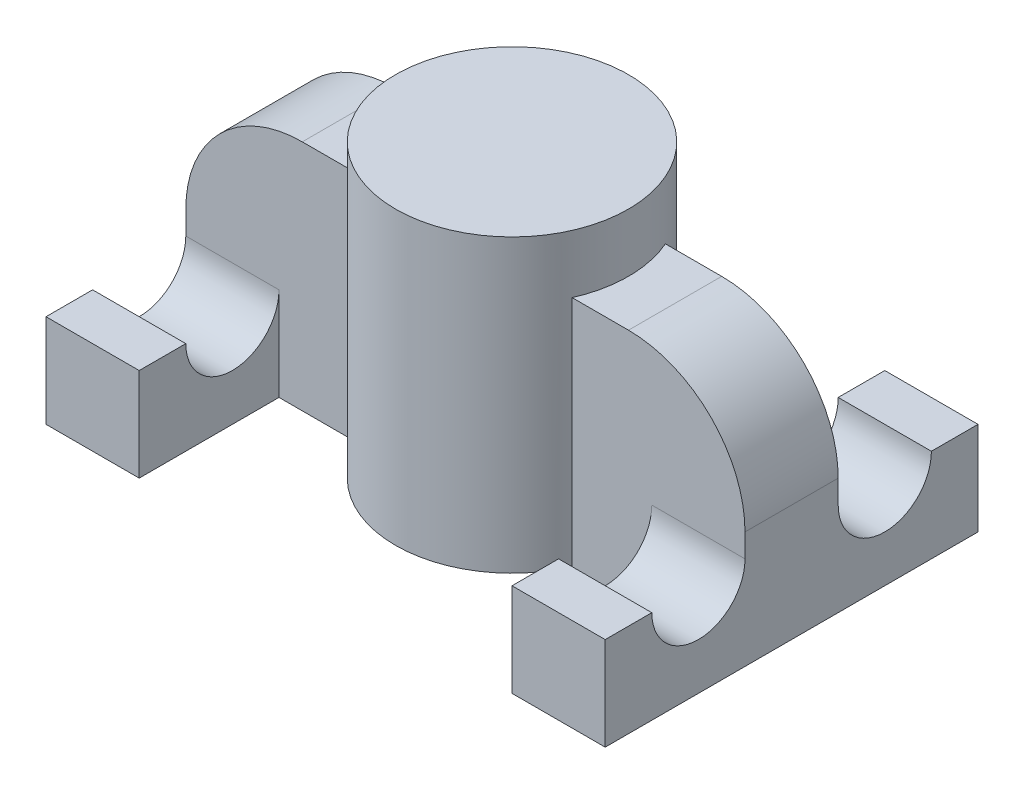
from build123d import *

# Parameters (mm, degrees)
SKETCH1_R                = 10
PEN_CAP_DEPTH            = 25
SKETCH2_W                = 48
SKETCH2_H                = 8
HOOK_STRUCTURE_DEPTH     = 20
PEN_CENTERING_HOLE_D     = 12.5
PEN_CENTERING_HOLE_DEPTH = 15
PEN_CENTERING_HOLE_TIP   = 6.25
HOOKS_DEPTH              = 8
CORNER_DEC_R             = 10


with BuildPart() as part:
    # Sketch1 → Pen Cap (new body)
    with BuildSketch(Plane(origin=(0, 0, 0), x_dir=(1, 0, 0), z_dir=(0, 1, 0))):
        Circle(SKETCH1_R)
    extrude(amount=PEN_CAP_DEPTH)

    # Sketch2 → Hook Structure (add)
    with BuildSketch(Plane.XZ):
        Rectangle(SKETCH2_W, SKETCH2_H)
    extrude(amount=-HOOK_STRUCTURE_DEPTH)

    # Pen Centering Hole
    with Locations(Plane.XZ):
        with Locations((0, 0)):
            Hole(PEN_CENTERING_HOLE_D / 2, depth=PEN_CENTERING_HOLE_DEPTH)
            with Locations((0, 0, -(PEN_CENTERING_HOLE_DEPTH + PEN_CENTERING_HOLE_TIP / 2))):  # 90° drill point
                Cone(0, PEN_CENTERING_HOLE_D / 2, PEN_CENTERING_HOLE_TIP, mode=Mode.SUBTRACT)

    # Sketch6 → Hooks (add)
    with BuildSketch(Plane(origin=(24, 0, 0), x_dir=(0, 0, -1), z_dir=(1, 0, 0))):
        with BuildLine():
            Line((-4, 0), (-16, 0))
            Line((-16, 0), (-16, 8))
            Line((-16, 8), (-12, 8))
            ThreePointArc((-12, 8), (-8, 4), (-4, 8))
            Line((-4, 8), (-4, 0))
        make_face()
        with BuildLine():
            Line((4, 8), (4, 0))
            Line((4, 0), (16, 0))
            Line((16, 0), (16, 8))
            Line((16, 8), (12, 8))
            ThreePointArc((12, 8), (8, 4), (4, 8))
        make_face()
    hooks = extrude(amount=-HOOKS_DEPTH)

    # Hook Mirror: Hooks across plane
    add(hooks.mirror(Plane(origin=(0, 0, 0), x_dir=(0, 0, 1), z_dir=(1, 0, 0))))

    # Corner Dec
    corner_dec_edges = [part.edges().sort_by_distance(p)[0] for p in [
        (-24, 20, 0),
        (24, 20, 0),
    ]]
    fillet(corner_dec_edges, radius=CORNER_DEC_R)


solid = part.part
